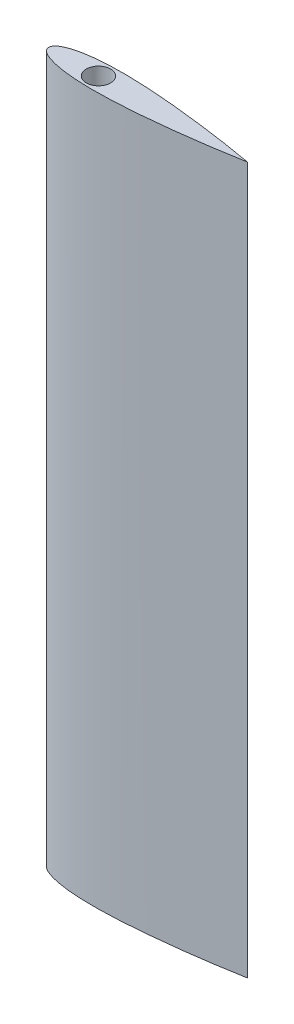
from build123d import *

# Parameters (mm, degrees)
SKETCH1_2_R        = 3.175
CUT_EXTRUDE2_DEPTH = 185.9184001


with BuildPart() as part:
    # rootSketch → Loft1 section 0
    with BuildSketch(Plane(origin=(0, 31.75, 0), x_dir=(1, 0, 0), z_dir=(0, 1, 0))):
        with BuildLine():
            add(Edge.make_bspline(
                [(0, 0), (-1.6572e-05, 0.056577364), (0.005364667, 0.148026672), (0.026073501, 0.280241396), (0.077769955, 0.452215412), (0.147060273, 0.611874915), (0.248525433, 0.785971359), (0.39236103, 0.977542518), (0.599181982, 1.195423819), (0.905829823, 1.451816919), (1.370469676, 1.757918922), (2.078266075, 2.119108524), (3.175731681, 2.542039428), (4.823252293, 2.99869744), (7.275411011, 3.452976612), (10.438659341, 3.780475746), (14.129329887, 3.929259057), (18.143568779, 3.896250983), (22.151742679, 3.722301475), (25.656241741, 3.475962342), (28.651461505, 3.213566971), (31.650711737, 2.914013348), (34.134157887, 2.639630917), (36.639458817, 2.336640809), (39.599525944, 1.953685828), (42.127939329, 1.60070159), (44.533194308, 1.24753169), (47.121130826, 0.837424538), (48.910319544, 0.545474341), (50.6553202, 0.241362714), (51.550989041, 0.081579679), (52, 0)],
                knots=[0, 0, 0, 0, 0, 0.003840944, 0.006235023, 0.009072291, 0.01219322, 0.015656839, 0.019917177, 0.025338962, 0.032592504, 0.042799388, 0.05770457, 0.079310668, 0.112503101, 0.158972616, 0.227236465, 0.295500326, 0.36376419, 0.432028053, 0.500291915, 0.534423847, 0.56855578, 0.636819643, 0.670951575, 0.705083508, 0.773347371, 0.807479302, 0.841611234, 0.875743167, 0.9098751, 0.9098751, 0.9098751, 0.9098751, 0.9098751], degree=4))
            add(Edge.make_bspline(
                [(0, 0), (-1.6572e-05, -0.056577364), (0.005364667, -0.148026672), (0.026073501, -0.280241396), (0.077769955, -0.452215412), (0.147060273, -0.611874915), (0.248525433, -0.785971359), (0.39236103, -0.977542518), (0.599181982, -1.195423819), (0.905829823, -1.451816919), (1.370469676, -1.757918922), (2.078266075, -2.119108524), (3.175731681, -2.542039428), (4.823252293, -2.99869744), (7.275411011, -3.452976612), (10.438659341, -3.780475746), (14.129329887, -3.929259057), (18.143568779, -3.896250983), (22.151742679, -3.722301475), (25.656241741, -3.475962342), (28.651461505, -3.213566971), (31.650711737, -2.914013348), (34.134157887, -2.639630917), (36.639458817, -2.336640809), (39.599525944, -1.953685828), (42.127939329, -1.60070159), (44.533194308, -1.24753169), (47.121130826, -0.837424538), (48.910319544, -0.545474341), (50.6553202, -0.241362714), (51.550989041, -0.081579679), (52, 0)],
                knots=[0, 0, 0, 0, 0, 0.003840944, 0.006235023, 0.009072291, 0.01219322, 0.015656839, 0.019917177, 0.025338962, 0.032592504, 0.042799388, 0.05770457, 0.079310668, 0.112503101, 0.158972616, 0.227236465, 0.295500326, 0.36376419, 0.432028053, 0.500291915, 0.534423847, 0.56855578, 0.636819643, 0.670951575, 0.705083508, 0.773347371, 0.807479302, 0.841611234, 0.875743167, 0.9098751, 0.9098751, 0.9098751, 0.9098751, 0.9098751], degree=4))
        make_face()
    # tipSketch → Loft1 section 1
    with BuildSketch(Plane(origin=(0, 216.6684, 0), x_dir=(1, 0, 0), z_dir=(0, 1, 0))):
        with BuildLine():
            add(Edge.make_bspline(
                [(0, 0), (-1.6572e-05, 0.056577364), (0.005364667, 0.148026672), (0.026073501, 0.280241396), (0.077769955, 0.452215412), (0.147060273, 0.611874915), (0.248525433, 0.785971359), (0.39236103, 0.977542518), (0.599181982, 1.195423819), (0.905829823, 1.451816919), (1.370469676, 1.757918922), (2.078266075, 2.119108524), (3.175731681, 2.542039428), (4.823252293, 2.99869744), (7.275411011, 3.452976612), (10.438659341, 3.780475746), (14.129329887, 3.929259057), (18.143568779, 3.896250983), (22.151742679, 3.722301475), (25.656241741, 3.475962342), (28.651461505, 3.213566971), (31.650711737, 2.914013348), (34.134157887, 2.639630917), (36.639458817, 2.336640809), (39.599525944, 1.953685828), (42.127939329, 1.60070159), (44.533194308, 1.24753169), (47.121130826, 0.837424538), (48.910319544, 0.545474341), (50.6553202, 0.241362714), (51.550989041, 0.081579679), (52, 0)],
                knots=[0, 0, 0, 0, 0, 0.003840944, 0.006235023, 0.009072291, 0.01219322, 0.015656839, 0.019917177, 0.025338962, 0.032592504, 0.042799388, 0.05770457, 0.079310668, 0.112503101, 0.158972616, 0.227236465, 0.295500326, 0.36376419, 0.432028053, 0.500291915, 0.534423847, 0.56855578, 0.636819643, 0.670951575, 0.705083508, 0.773347371, 0.807479302, 0.841611234, 0.875743167, 0.9098751, 0.9098751, 0.9098751, 0.9098751, 0.9098751], degree=4))
            add(Edge.make_bspline(
                [(0, 0), (-1.6572e-05, -0.056577364), (0.005364667, -0.148026672), (0.026073501, -0.280241396), (0.077769955, -0.452215412), (0.147060273, -0.611874915), (0.248525433, -0.785971359), (0.39236103, -0.977542518), (0.599181982, -1.195423819), (0.905829823, -1.451816919), (1.370469676, -1.757918922), (2.078266075, -2.119108524), (3.175731681, -2.542039428), (4.823252293, -2.99869744), (7.275411011, -3.452976612), (10.438659341, -3.780475746), (14.129329887, -3.929259057), (18.143568779, -3.896250983), (22.151742679, -3.722301475), (25.656241741, -3.475962342), (28.651461505, -3.213566971), (31.650711737, -2.914013348), (34.134157887, -2.639630917), (36.639458817, -2.336640809), (39.599525944, -1.953685828), (42.127939329, -1.60070159), (44.533194308, -1.24753169), (47.121130826, -0.837424538), (48.910319544, -0.545474341), (50.6553202, -0.241362714), (51.550989041, -0.081579679), (52, 0)],
                knots=[0, 0, 0, 0, 0, 0.003840944, 0.006235023, 0.009072291, 0.01219322, 0.015656839, 0.019917177, 0.025338962, 0.032592504, 0.042799388, 0.05770457, 0.079310668, 0.112503101, 0.158972616, 0.227236465, 0.295500326, 0.36376419, 0.432028053, 0.500291915, 0.534423847, 0.56855578, 0.636819643, 0.670951575, 0.705083508, 0.773347371, 0.807479302, 0.841611234, 0.875743167, 0.9098751, 0.9098751, 0.9098751, 0.9098751, 0.9098751], degree=4))
        make_face()
    loft()

    # Sketch1_2 → Cut-Extrude2 (cut, through all)
    with BuildSketch(Plane(origin=(0, 31.75, 0), x_dir=(1, 0, 0), z_dir=(0, 1, 0))):
        with Locations((12.999969404, 0)):
            Circle(SKETCH1_2_R)
    extrude(amount=CUT_EXTRUDE2_DEPTH, mode=Mode.SUBTRACT)


solid = part.part
